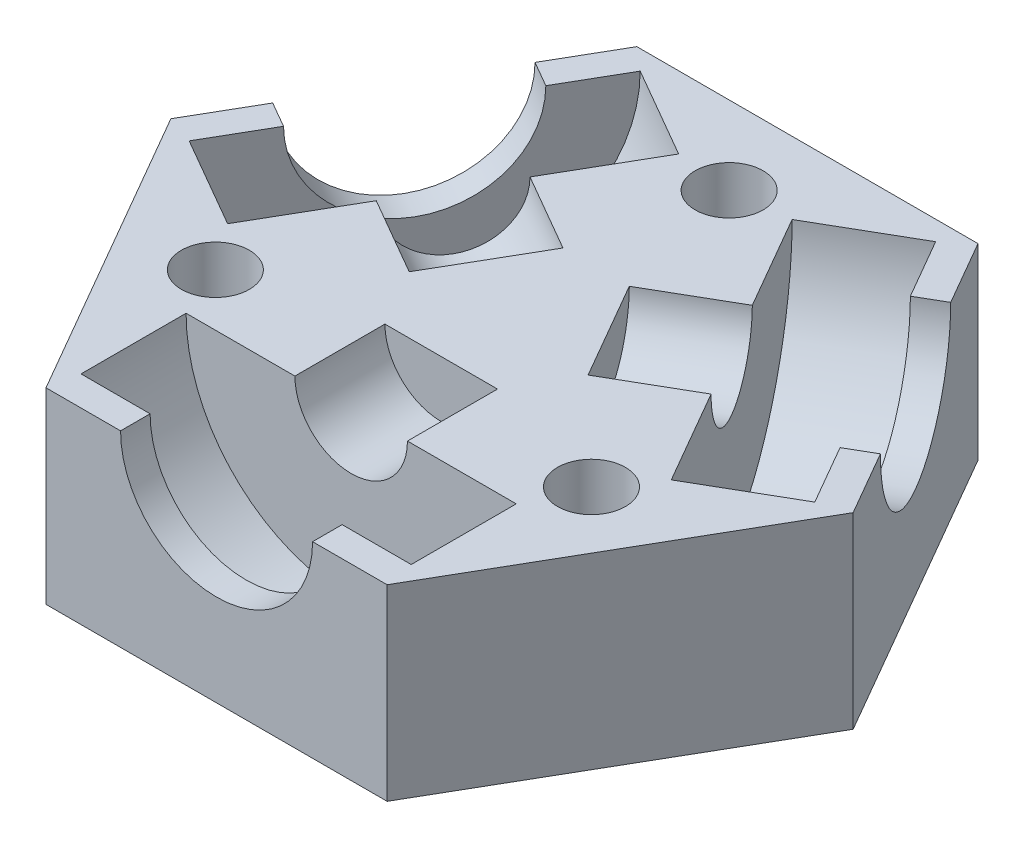
from build123d import *

# Parameters (mm, degrees)
BOSS_EXTRUDE1_DEPTH = 12.7
CIRPATTERN1_COUNT   = 3
SKETCH7_R           = 2.3
CUT_EXTRUDE2_DEPTH  = 6.35


with BuildPart() as part:
    # Sketch1 → Boss-Extrude1 (new body)
    with BuildSketch(Plane(origin=(0, 0, 0), x_dir=(1, 0, 0), z_dir=(0, 1, 0))):
        Polygon((11.547005384, -20), (23.094010768, 0), (11.547005384, 20), (-11.547005384, 20), (-23.094010768, 0), (-11.547005384, -20), align=None)
    extrude(amount=BOSS_EXTRUDE1_DEPTH)

    # Sketch5 → Cut-Revolve1 (revolve, cut)
    with BuildSketch(Plane(origin=(0, 12.7, 0), x_dir=(1, 0, 0), z_dir=(0, 1, 0))):
        Polygon((0, -20), (0, -4.792), (-3.81, -4.792), (-3.81, -10.888), (-11.176, -10.888), (-11.176, -18), (-6.5, -18), (-6.5, -20), align=None)
    cut_revolve1 = revolve(axis=Axis((0, 12.7, 20), (0, 0, -1)), mode=Mode.SUBTRACT)

    # CirPattern1: Cut-Revolve1 ×3 about axis
    cirpattern1_axis = Axis((0, -0.635, 0), (0, 1, 0))
    for i in range(1, CIRPATTERN1_COUNT):
        add(cut_revolve1.rotate(cirpattern1_axis, i * 360 / CIRPATTERN1_COUNT), mode=Mode.SUBTRACT)

    # Sketch7 → Cut-Extrude2 (cut)
    with BuildSketch(Plane(origin=(0, 12.7, 0), x_dir=(1, 0, 0), z_dir=(0, 1, 0))):
        with Locations((0, 14.700006)):
            Circle(SKETCH7_R)
        with Locations((12.730575168, -7.349997)):
            Circle(SKETCH7_R)
        with Locations((-12.730575168, -7.349997)):
            Circle(SKETCH7_R)
    extrude(amount=-CUT_EXTRUDE2_DEPTH, mode=Mode.SUBTRACT)


solid = part.part
